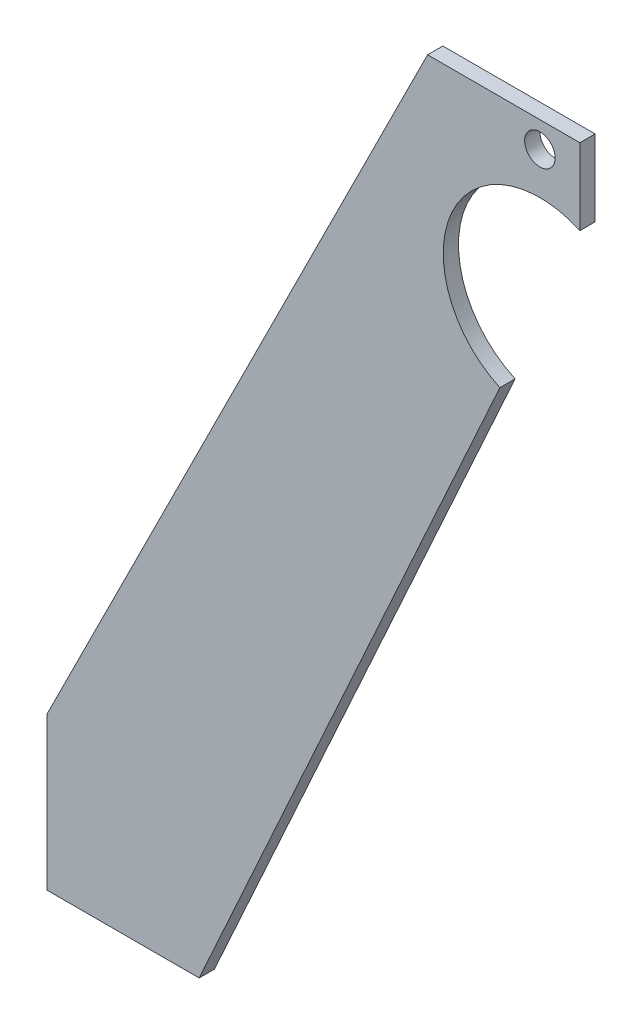
from build123d import *

# Parameters (mm, degrees)
SKETCH1_R           = 4
BOSS_EXTRUDE1_DEPTH = 4


with BuildPart() as part:
    # Sketch1 → Boss-Extrude1 (new body)
    with BuildSketch(Plane.XY):
        with BuildLine():
            Line((0, 0), (0, -40))
            Line((0, -40), (40, -40))
            Line((40, -40), (118.991479096, 133.781254012))
            ThreePointArc((118.991479096, 133.781254012), (106.386366554, 167.394887458), (140, 180))
            Line((140, 180), (140, 200))
            Line((140, 200), (100, 200))
            Line((100, 200), (0, 0))
        make_face()
        with Locations((129.495739548, 193.231222879)):
            Circle(SKETCH1_R, mode=Mode.SUBTRACT)
    extrude(amount=BOSS_EXTRUDE1_DEPTH)


solid = part.part
